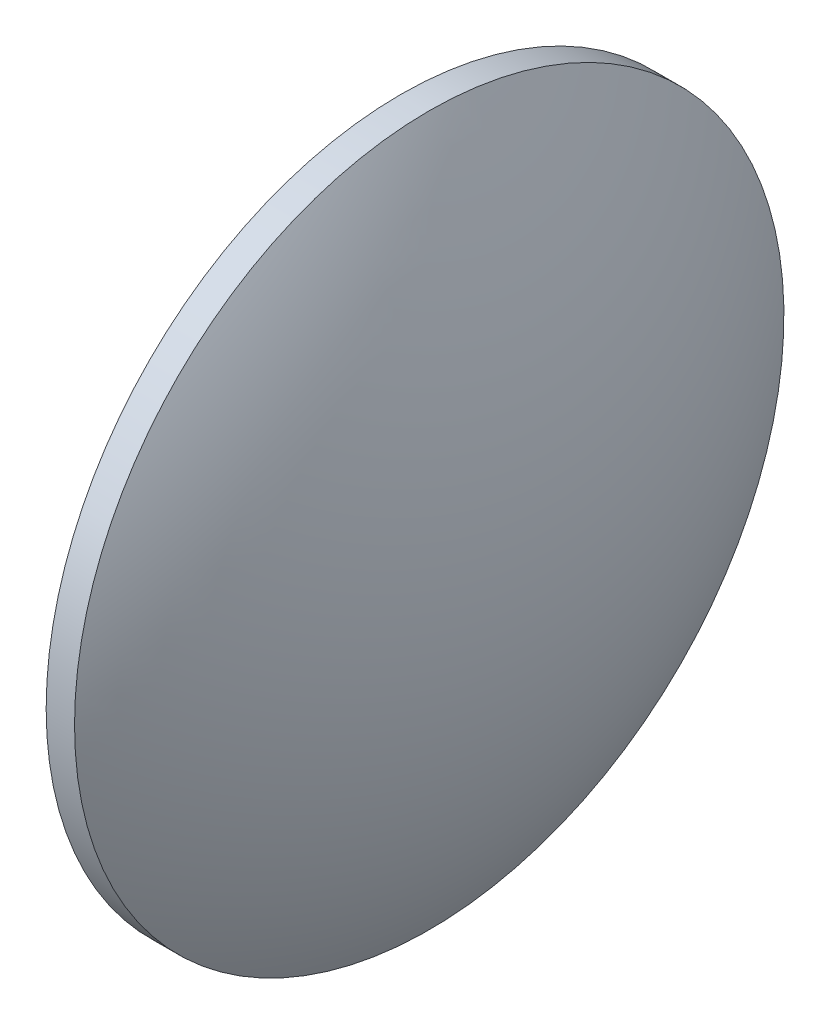
from build123d import *

# Parameters (mm, degrees)
SKETCH_1_ONE_SIDE_W = 4
SKETCH_1_ONE_SIDE_H = 50


with BuildPart() as part:
    # 草图1 one side → 旋转1 (revolve)
    with BuildSketch(Plane.XY):
        with Locations((340.386589664, 216.402019776)):
            Rectangle(SKETCH_1_ONE_SIDE_W, SKETCH_1_ONE_SIDE_H)
        with BuildLine():
            Line((324.626589664, 191.402019776), (338.386589664, 191.402019776))
            Line((338.386589664, 191.402019776), (338.386589664, 241.402019776))
            ThreePointArc((338.386589664, 241.402019776), (328.129366294, 217.331431648), (324.626589664, 191.402019776))
        make_face()
        with BuildLine():
            Line((342.386589664, 191.402019776), (356.146589664, 191.402019776))
            ThreePointArc((356.146589664, 191.402019776), (352.643813034, 217.331431648), (342.386589664, 241.402019776))
            Line((342.386589664, 241.402019776), (342.386589664, 191.402019776))
        make_face()
    revolve(axis=Axis((315.881910425, 191.402019776, 0), (1, 0, 0)))


solid = part.part
